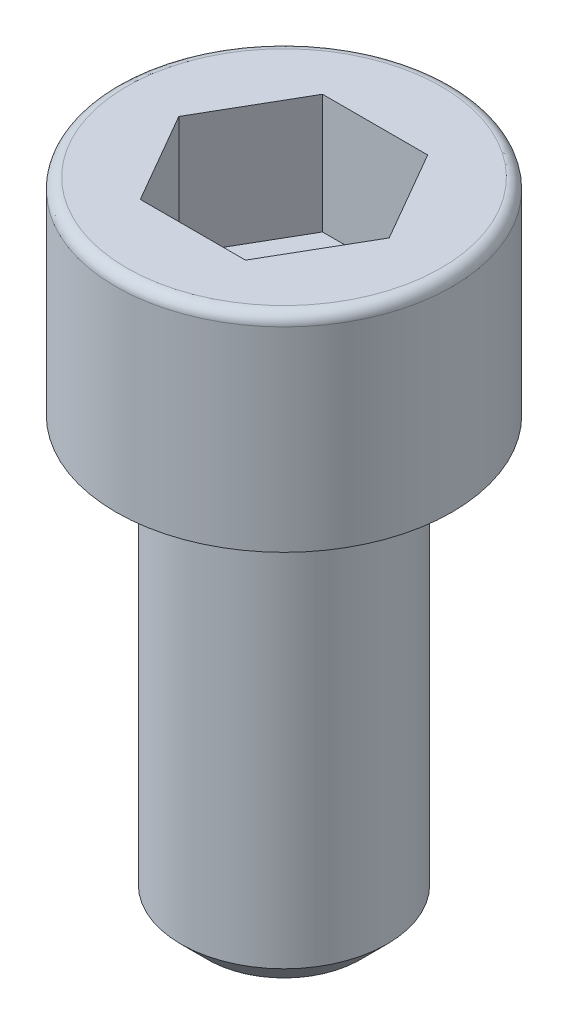
from build123d import *

# Parameters (mm, degrees)
SKETCH1_R           = 3.875
BOSS_EXTRUDE1_DEPTH = 4.75
FILLET1_R           = 0.25
CUT_EXTRUDE1_DEPTH  = 2.75
SKETCH3_R           = 2.375
BOSS_EXTRUDE2_DEPTH = 10


with BuildPart() as part:
    # Sketch1 → Boss-Extrude1 (new body)
    with BuildSketch(Plane(origin=(0, 0, 0), x_dir=(1, 0, 0), z_dir=(0, 1, 0))):
        Circle(SKETCH1_R)
    extrude(amount=BOSS_EXTRUDE1_DEPTH)

    # Fillet1
    fillet1_edges = [part.edges().sort_by_distance(p)[0] for p in [
        (-3.875, 4.75, 0),
    ]]
    fillet(fillet1_edges, radius=FILLET1_R)

    # Sketch2 → Cut-Extrude1 (cut)
    with BuildSketch(Plane(origin=(0, 4.75, 0), x_dir=(1, 0, 0), z_dir=(0, 1, 0))):
        Polygon((-2.424871131, 0), (-1.212435565, -2.1), (1.212435565, -2.1), (2.424871131, 0), (1.212435565, 2.1), (-1.212435565, 2.1), align=None)
    extrude(amount=-CUT_EXTRUDE1_DEPTH, mode=Mode.SUBTRACT)

    # Sketch3 → Boss-Extrude2 (add)
    with BuildSketch(Plane.XZ):
        Circle(SKETCH3_R)
    extrude(amount=BOSS_EXTRUDE2_DEPTH)

    # Sketch4 → Cut-Revolve1 (revolve, cut)
    with BuildSketch(Plane(origin=(0, 0, 0), x_dir=(0, 0, -1), z_dir=(1, 0, 0))):
        Polygon((-2.375, -10), (-2.375, -9.375), (-1.75, -10), align=None)
    revolve(axis=Axis((0, -10, 0), (0, 1, 0)), mode=Mode.SUBTRACT)


solid = part.part
